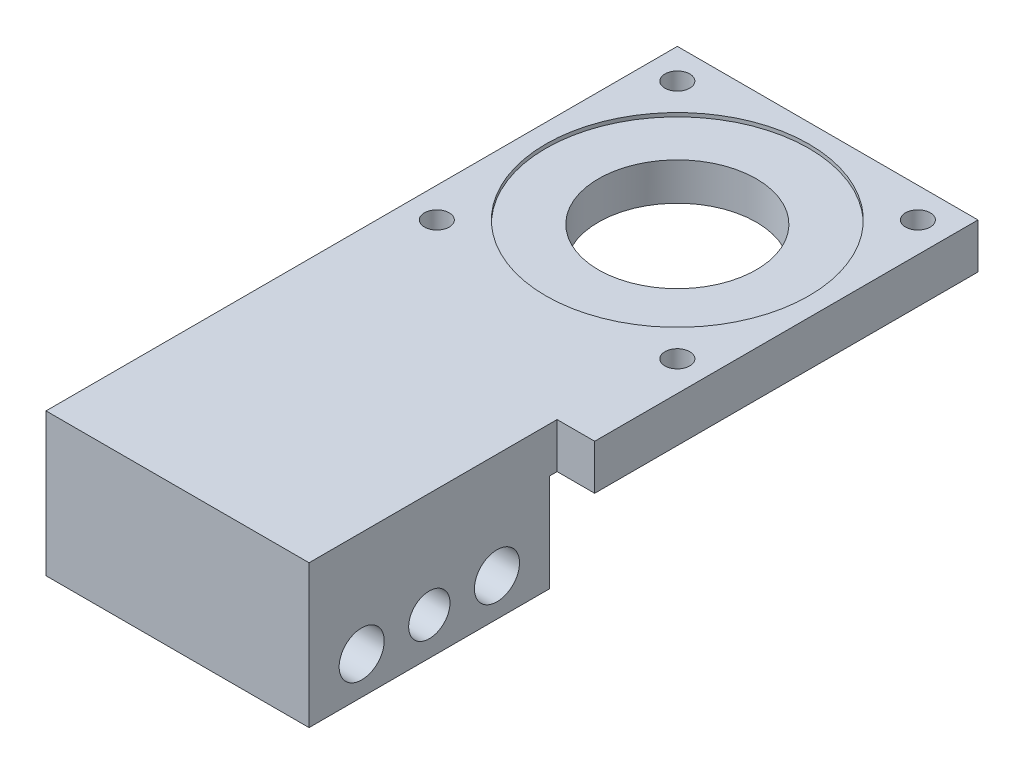
from build123d import *

# Parameters (mm, degrees)
SKETCH1_W             = 40
SKETCH1_H             = 84
SKETCH1_R             = 10.5
BOSS_EXTRUDE1_DEPTH   = 6
SKETCH2_W             = 40
SKETCH2_H             = 32
BOSS_EXTRUDE2_DEPTH   = 13
F_6_0MM_DOWEL_HOLE1_D = 6
M5_CLEARANCE_HOLE1_D  = 5.5
M4X0_7_TAPPED_HOLE1_D = 3.3
SKETCH12_R            = 17.5
CUT_EXTRUDE1_DEPTH    = 0.5
SKETCH13_R            = 17.5
CUT_EXTRUDE2_DEPTH    = 0.5
SKETCH14_W            = 33
SKETCH14_H            = 19
CUT_EXTRUDE3_DEPTH    = 5


with BuildPart() as part:
    # Sketch1 → Boss-Extrude1 (new body)
    with BuildSketch(Plane(origin=(0, 0, 0), x_dir=(1, 0, 0), z_dir=(0, 1, 0))):
        with Locations((0, -22)):
            Rectangle(SKETCH1_W, SKETCH1_H)
        Circle(SKETCH1_R, mode=Mode.SUBTRACT)
    extrude(amount=BOSS_EXTRUDE1_DEPTH)

    # Sketch2 → Boss-Extrude2 (add)
    with BuildSketch(Plane.XZ):
        with Locations((0, 48)):
            Rectangle(SKETCH2_W, SKETCH2_H)
    extrude(amount=BOSS_EXTRUDE2_DEPTH)

    # Ø6.0mm Dowel Hole1 (through all)
    with Locations(Plane(origin=(20, 0, 0), x_dir=(0, 0, -1), z_dir=(1, 0, 0))):
        with Locations((-57, -8), (-39, -8)):
            Hole(F_6_0MM_DOWEL_HOLE1_D / 2)

    # M5 Clearance Hole1 (through all)
    with Locations(Plane.ZY.offset(20)):
        with Locations((48, -8)):
            Hole(M5_CLEARANCE_HOLE1_D / 2)

    # M4x0.7 Tapped Hole1 (through all)
    with Locations(Plane(origin=(0, 0, 0), x_dir=(-1, 0, 0), z_dir=(0, -1, 0))):
        with Locations((16, 16), (-16, 16), (-16, -16), (16, -16)):
            Hole(M4X0_7_TAPPED_HOLE1_D / 2)

    # Sketch12 → Cut-Extrude1 (cut)
    with BuildSketch(Plane(origin=(0, 6, 0), x_dir=(1, 0, 0), z_dir=(0, 1, 0))):
        Circle(SKETCH12_R)
    extrude(amount=-CUT_EXTRUDE1_DEPTH, mode=Mode.SUBTRACT)

    # Sketch13 → Cut-Extrude2 (cut)
    with BuildSketch(Plane.XZ):
        Circle(SKETCH13_R)
    extrude(amount=-CUT_EXTRUDE2_DEPTH, mode=Mode.SUBTRACT)

    # Sketch14 → Cut-Extrude3 (cut)
    with BuildSketch(Plane(origin=(20, 0, 0), x_dir=(0, 0, -1), z_dir=(1, 0, 0))):
        with Locations((-47.5, -3.5)):
            Rectangle(SKETCH14_W, SKETCH14_H)
    extrude(amount=-CUT_EXTRUDE3_DEPTH, mode=Mode.SUBTRACT)


solid = part.part
